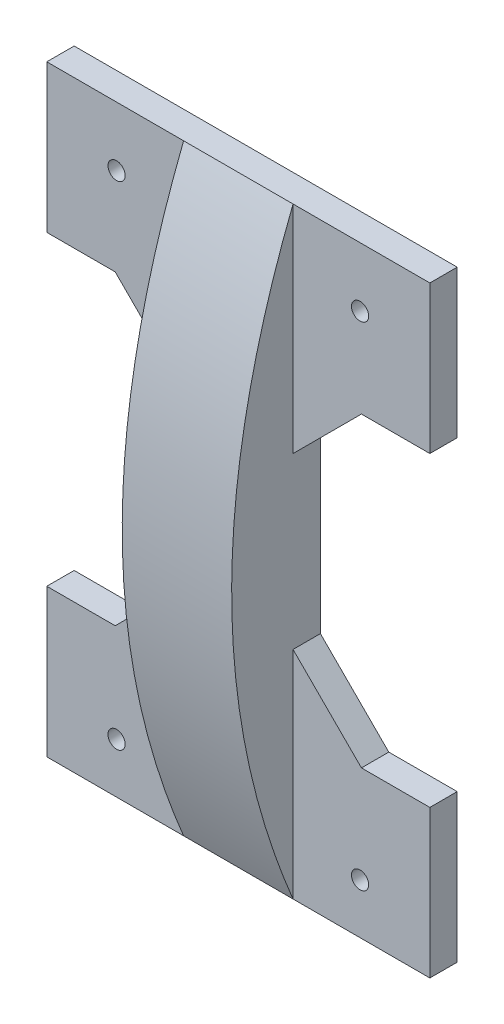
from build123d import *

# Parameters (mm, degrees)
SKETCH_1_W          = 70
SKETCH_1_H          = 110
EXTRUDE_1_DEPTH     = 5
SKETCH_2_R          = 1.57
CUT_EXTRUDE_1_DEPTH = 5
CUT_EXTRUDE_2_DEPTH = 5
EXTRUDE_START       = -20
EXTRUDE_3_DEPTH     = 20


with BuildPart() as part:
    # 草图1 → 凸台-拉伸1 (new body)
    with BuildSketch(Plane.XY):
        with Locations((-7.671321449, -10.342578999)):
            Rectangle(SKETCH_1_W, SKETCH_1_H)
    extrude(amount=EXTRUDE_1_DEPTH)

    # 草图2 → 切除-拉伸1 (cut)
    with BuildSketch(Plane.XY.offset(5)):
        with Locations((-29.921321449, 33.811245296)):
            Circle(SKETCH_2_R)
        with Locations((14.578678551, 33.811245296)):
            Circle(SKETCH_2_R)
        with Locations((-29.921321449, -56.188754704)):
            Circle(SKETCH_2_R)
        with Locations((14.578678551, -56.188754704)):
            Circle(SKETCH_2_R)
    extrude(amount=-CUT_EXTRUDE_1_DEPTH, mode=Mode.SUBTRACT)

    # 草图3 → 切除-拉伸2 (cut)
    with BuildSketch(Plane.XY.offset(5)):
        Polygon((-42.671321449, 17.657421001), (-30.171321449, 17.657421001), (-17.671321449, 5.157421001), (-17.671321449, -25.842578999), (-30.171321449, -38.342578999), (-42.671321449, -38.342578999), align=None)
        Polygon((14.828678551, 17.657421001), (27.328678551, 17.657421001), (27.328678551, -38.342578999), (14.828678551, -38.342578999), (2.328678551, -25.842578999), (2.328678551, 5.157421001), align=None)
    extrude(amount=-CUT_EXTRUDE_2_DEPTH, mode=Mode.SUBTRACT)

    # 草图6 → 凸台-拉伸3 (add)
    with BuildSketch(Plane(origin=(2.328678551, 0, 0), x_dir=(0, 0, -1), z_dir=(1, 0, 0)).offset(EXTRUDE_START)):
        with BuildLine():
            Line((-5, 44.657421001), (-5, -65.342578999))
            add(Edge.make_bspline(
                [(-5, 44.657421001), (-27.43165177, -11.855516643), (-5, -65.342578999)],
                knots=[0, 0, 0, 1, 1, 1], degree=2))
        make_face()
    extrude(amount=EXTRUDE_3_DEPTH)


solid = part.part
